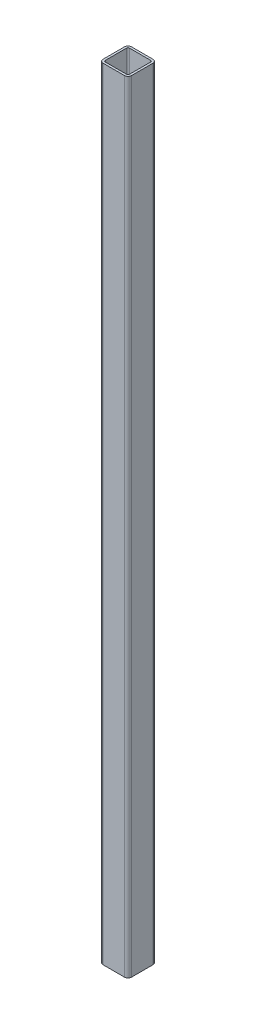
from build123d import *

# Parameters (mm, degrees)
EXTRUDE_1_DEPTH = 1100


with BuildPart() as part:
    # Эскиз1 → Вытянуть-Тонкостенный1 (new body)
    with BuildSketch(Plane(origin=(0, 0, 0), x_dir=(1, 0, 0), z_dir=(0, 1, 0))):
        with BuildLine():
            Line((-15, 20), (15, 20))
            ThreePointArc((15, 20), (18.535533906, 18.535533906), (20, 15))
            Line((20, 15), (20, -15))
            ThreePointArc((20, -15), (18.535533906, -18.535533906), (15, -20))
            Line((15, -20), (-15, -20))
            ThreePointArc((-15, -20), (-18.535533906, -18.535533906), (-20, -15))
            Line((-20, -15), (-20, 15))
            ThreePointArc((-20, 15), (-18.535533906, 18.535533906), (-15, 20))
        make_face()
        with BuildLine():
            Line((-15, 17), (15, 17))
            ThreePointArc((15, 17), (16.414213562, 16.414213562), (17, 15))
            Line((17, 15), (17, -15))
            ThreePointArc((17, -15), (16.414213562, -16.414213562), (15, -17))
            Line((15, -17), (-15, -17))
            ThreePointArc((-15, -17), (-16.414213562, -16.414213562), (-17, -15))
            Line((-17, -15), (-17, 15))
            ThreePointArc((-17, 15), (-16.414213562, 16.414213562), (-15, 17))
        make_face(mode=Mode.SUBTRACT)
    extrude(amount=EXTRUDE_1_DEPTH)


solid = part.part
